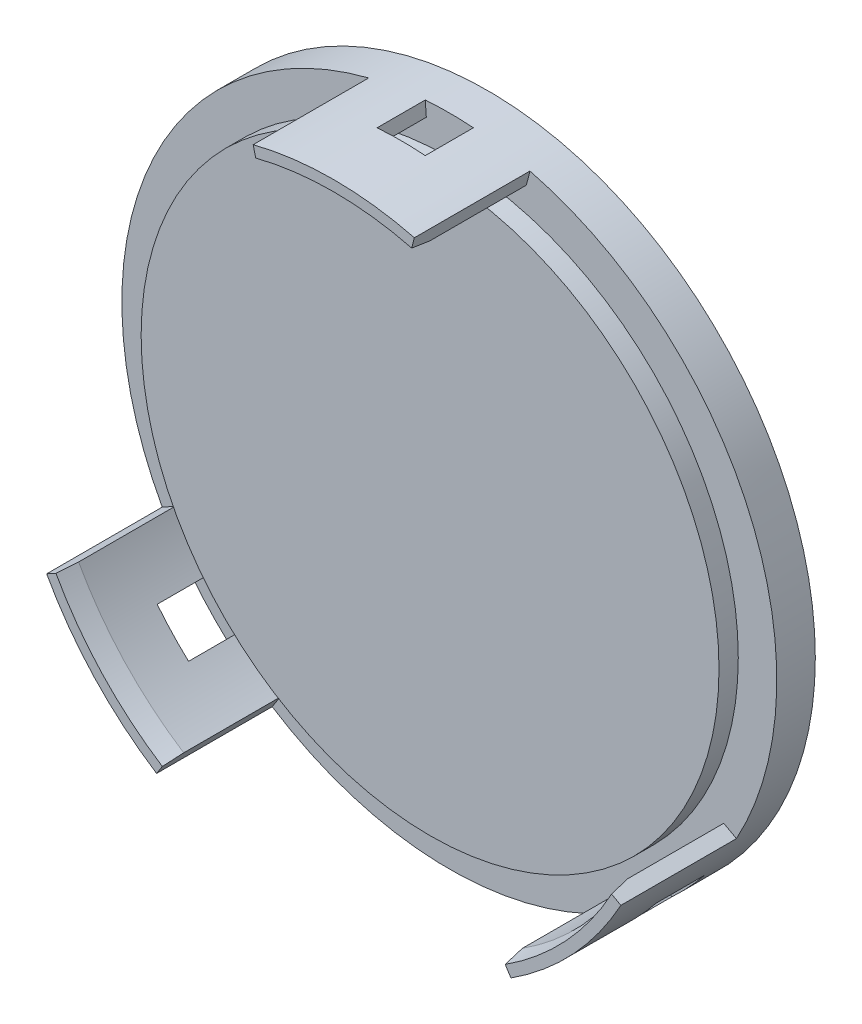
from build123d import *

# Parameters (mm, degrees)
SKETCH1_R                                   = 17
SKETCH1_R_2                                 = 15
BOSS_EXTRUDE1_DEPTH                         = 2
SKETCH1_2_R                                 = 15
BOSS_EXTRUDE2_DEPTH                         = 3
BOSS_EXTRUDE3_DEPTH                         = 6
CUT_EXTRUDE1_START                          = -6
CUT_EXTRUDE1_DEPTH                          = 2.5
CHAMFER1_SIZE                               = 1
CHAMFER1_SIZE2                              = 0.2
CIRPATTERN1_COUNT                           = 2
CIRPATTERN1_ANGLE                           = 133
CHAMFER1_OF_CIRPATTERN1_SIZE2               = 0.2
CHAMFER1_OF_CIRPATTERN1_SIZE                = 1
CIRPATTERN1_THE_OTHER_WAY_COUNT             = 2
CIRPATTERN1_THE_OTHER_WAY_ANGLE             = 133
CHAMFER1_OF_CIRPATTERN1_THE_OTHER_WAY_SIZE2 = 0.2
CHAMFER1_OF_CIRPATTERN1_THE_OTHER_WAY_SIZE  = 1


with BuildPart() as part:
    # Sketch1 → Boss-Extrude1 (new body)
    with BuildSketch(Plane.XY):
        Circle(SKETCH1_R)
        Circle(SKETCH1_R_2, mode=Mode.SUBTRACT)
    extrude(amount=BOSS_EXTRUDE1_DEPTH)

    # Sketch1_2 → Boss-Extrude2 (add)
    with BuildSketch(Plane.XY):
        Circle(SKETCH1_2_R)
    extrude(amount=BOSS_EXTRUDE2_DEPTH)

    # Sketch2 → Boss-Extrude3 (add)
    with BuildSketch(Plane.XY.offset(2)):
        with BuildLine():
            ThreePointArc((4.184615385, 16.476923077), (0, 17), (-4.184615385, 16.476923077))
            Line((-4.184615385, 16.476923077), (-4, 15.75))
            ThreePointArc((-4, 15.75), (0, 16.25), (4, 15.75))
            Line((4, 15.75), (4.184615385, 16.476923077))
        make_face()
    boss_extrude3 = extrude(amount=BOSS_EXTRUDE3_DEPTH)

    # Sketch3 → Cut-Extrude1 (cut)
    with BuildSketch(Plane.XY.offset(8).offset(CUT_EXTRUDE1_START)):
        with BuildLine():
            ThreePointArc((1.25, 16.953981833), (0, 17), (-1.25, 16.953981833))
            Line((-1.25, 16.953981833), (-1.194852941, 16.206012046))
            ThreePointArc((-1.194852941, 16.206012046), (0, 16.25), (1.194852941, 16.206012046))
            Line((1.194852941, 16.206012046), (1.25, 16.953981833))
        make_face()
    cut_extrude1 = extrude(amount=CUT_EXTRUDE1_DEPTH, mode=Mode.SUBTRACT)

    # Chamfer1
    chamfer1_edges = [part.edges().sort_by_distance(p)[0] for p in [
        (0, 16.25, 8),
    ]]
    chamfer1_side = [part.faces().sort_by_distance(p)[0] for p in [
        (0, 16.25, 5),
    ]]
    chamfer(chamfer1_edges, length=CHAMFER1_SIZE, length2=CHAMFER1_SIZE2, reference=chamfer1_side[0])

    # CirPattern1: Boss-Extrude3, Cut-Extrude1 ×2 about axis
    cirpattern1_axis = Axis((0, 0, 0), (0, 0, -1))
    for i in range(1, CIRPATTERN1_COUNT):
        add(boss_extrude3.rotate(cirpattern1_axis, i * CIRPATTERN1_ANGLE / (CIRPATTERN1_COUNT - 1)))
        add(cut_extrude1.rotate(cirpattern1_axis, i * CIRPATTERN1_ANGLE / (CIRPATTERN1_COUNT - 1)), mode=Mode.SUBTRACT)

    # Chamfer1 of CirPattern1
    chamfer1_of_cirpattern1_edges = [part.edges().sort_by_distance(p)[0] for p in [
        (11.884497651, -11.082473351, 8),
    ]]
    chamfer(chamfer1_of_cirpattern1_edges, length=CHAMFER1_OF_CIRPATTERN1_SIZE, length2=CHAMFER1_OF_CIRPATTERN1_SIZE2)

    # CirPattern1 the other way: Boss-Extrude3, Cut-Extrude1 ×2 about axis
    cirpattern1_the_other_way_axis = Axis((0, 0, 0), (0, 0, 1))
    for i in range(1, CIRPATTERN1_THE_OTHER_WAY_COUNT):
        add(boss_extrude3.rotate(cirpattern1_the_other_way_axis, i * CIRPATTERN1_THE_OTHER_WAY_ANGLE / (CIRPATTERN1_THE_OTHER_WAY_COUNT - 1)))
        add(cut_extrude1.rotate(cirpattern1_the_other_way_axis, i * CIRPATTERN1_THE_OTHER_WAY_ANGLE / (CIRPATTERN1_THE_OTHER_WAY_COUNT - 1)), mode=Mode.SUBTRACT)

    # Chamfer1 of CirPattern1 the other way
    chamfer1_of_cirpattern1_the_other_way_edges = [part.edges().sort_by_distance(p)[0] for p in [
        (-11.884497651, -11.082473351, 8),
    ]]
    chamfer(chamfer1_of_cirpattern1_the_other_way_edges, length=CHAMFER1_OF_CIRPATTERN1_THE_OTHER_WAY_SIZE, length2=CHAMFER1_OF_CIRPATTERN1_THE_OTHER_WAY_SIZE2)


solid = part.part
